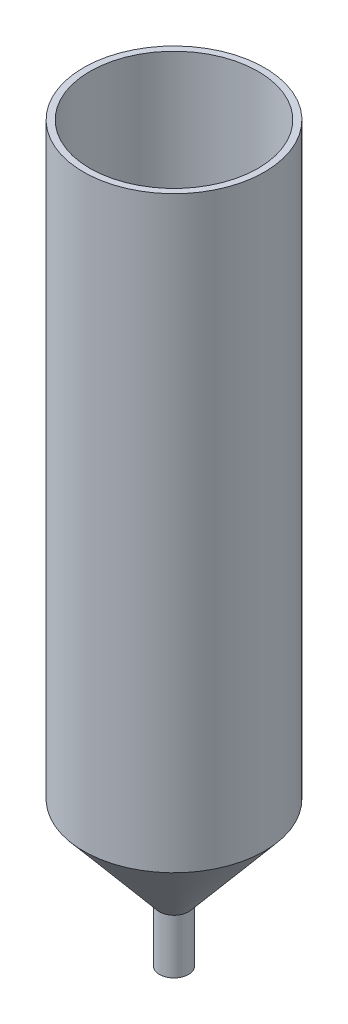
from build123d import *


with BuildPart() as part:
    # Sketch1 → Revolve2 (revolve)
    with BuildSketch(Plane.XY):
        Polygon((-18.581601377, 0), (-18.581601377, -129.483745121), (-2.218007376, -148.985117058), (-2.218007376, -162), (-3.218007376, -162), (-3.218007376, -150), (-20, -130), (-20, 0), align=None)
    revolve(axis=Axis((1.48e-07, 8.000543494, 0), (0, -1, 0)))


solid = part.part
